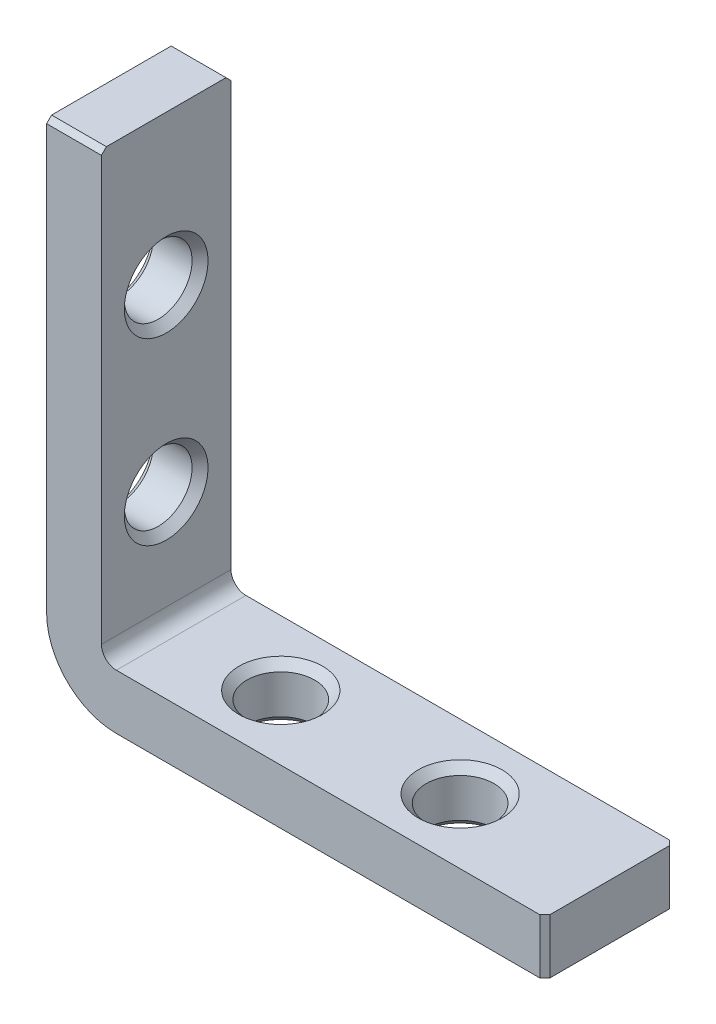
from build123d import *

# Parameters (mm, degrees)
EXTRUDE_1_DEPTH            = 6.5
HOLE_WIZARD_M81_AT_2_COUNT = 2
HOLE_WIZARD_M81_AT_2_PITCH = 18
CHAMFER_1_SIZE             = 0.5


with BuildPart() as part:
    # Эскиз1 → Бобышка-Вытянуть1 (new body, symmetric)
    with BuildSketch(Plane.XY):
        with BuildLine():
            Line((0, 50), (0, 7))
            ThreePointArc((0, 7), (2.050252532, 2.050252532), (7, 0))
            Line((7, 0), (50, 0))
            Line((50, 0), (50, 5.5))
            Line((50, 5.5), (7, 5.5))
            ThreePointArc((7, 5.5), (5.939339828, 5.939339828), (5.5, 7))
            Line((5.5, 7), (5.5, 50))
            Line((5.5, 50), (0, 50))
        make_face()
    extrude(amount=EXTRUDE_1_DEPTH, both=True)

    # Эскиз5 → Отверстие обработанное метчиком M81 (revolve, cut)
    with BuildSketch(Plane.ZX.offset(35)):
        Polygon((0, 0), (0, 5.5), (4.2, 5.5), (3.4, 4.7), (3.4, 0.8), (4.2, 0), align=None)
    hole_wizard_m81 = revolve(axis=Axis((-6.35, 35, 0), (1, 0, 0)), mode=Mode.SUBTRACT)

    # Отверстие обработанное метчиком M81 at 2: Отверстие обработанное метчиком M81 ×2
    with Locations(*[(0, -i * HOLE_WIZARD_M81_AT_2_PITCH, 0) for i in range(1, HOLE_WIZARD_M81_AT_2_COUNT)]):
        add(hole_wizard_m81, mode=Mode.SUBTRACT)

    # Зеркальное отражение1: Отверстие обработанное метчиком M81 across plane
    add(hole_wizard_m81.mirror(Plane(origin=(0, 0, 0), x_dir=(0, 0, 1), z_dir=(-0.707106781, 0.707106781, 0))), mode=Mode.SUBTRACT)

    # Зеркальное отражение1 copy 1 sketch → Зеркальное отражение1 copy 1 (revolve, cut)
    with BuildSketch(Plane(origin=(17, 0, 0), x_dir=(0, 0, 1), z_dir=(1, 0, 0))):
        Polygon((0, 0), (0, -5.5), (4.2, -5.5), (3.4, -4.7), (3.4, -0.8), (4.2, 0), align=None)
    revolve(axis=Axis((17, -6.35, 0), (0, -1, 0)), mode=Mode.SUBTRACT)

    # Фаска1
    chamfer_1_edges = [part.edges().sort_by_distance(p)[0] for p in [
        (2.75, 50, -6.5),
        (50, 2.75, 6.5),
        (2.75, 50, 6.5),
        (50, 2.75, -6.5),
    ]]
    chamfer(chamfer_1_edges, length=CHAMFER_1_SIZE)


solid = part.part
